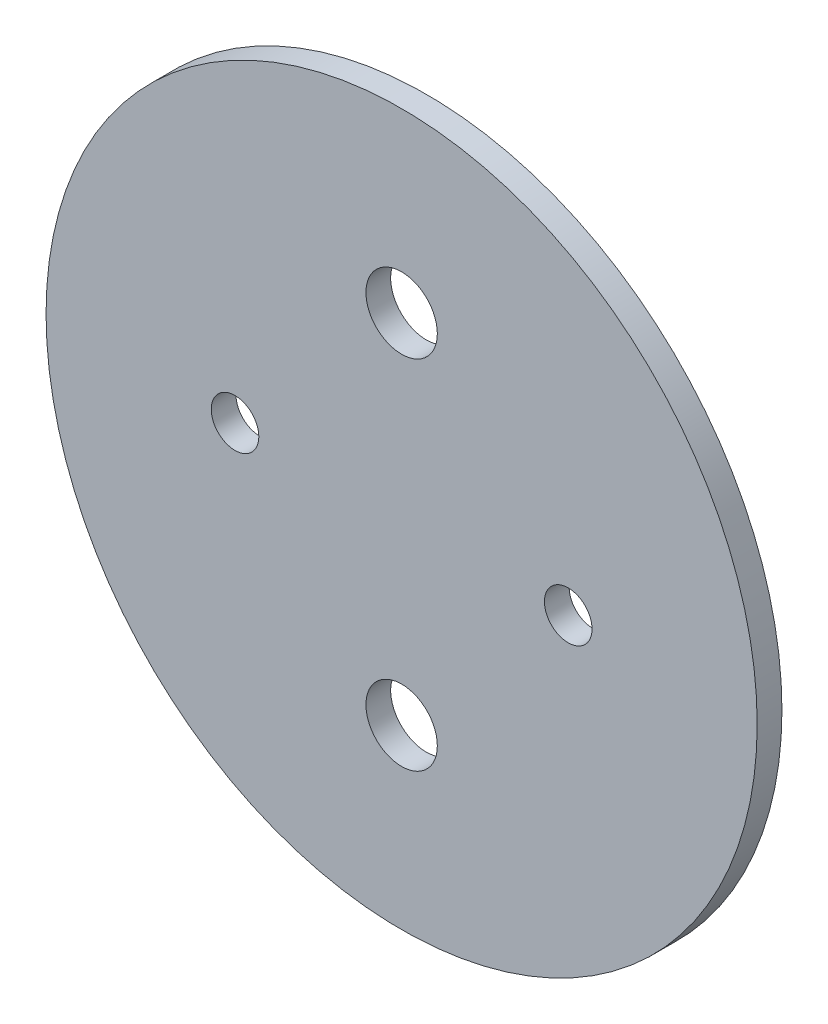
from build123d import *

# Parameters (mm, degrees)
SKETCH1_R           = 47.4345
SKETCH1_R_2         = 3.175
SKETCH1_R_3         = 4.7625
BOSS_EXTRUDE1_DEPTH = 3.302


with BuildPart() as part:
    # Sketch1 → Boss-Extrude1 (new body)
    with BuildSketch(Plane.XY):
        Circle(SKETCH1_R)
        with Locations((-22.225, 0)):
            Circle(SKETCH1_R_2, mode=Mode.SUBTRACT)
        with Locations((22.225, 0)):
            Circle(SKETCH1_R_2, mode=Mode.SUBTRACT)
        with Locations((0, -23.8125)):
            Circle(SKETCH1_R_3, mode=Mode.SUBTRACT)
        with Locations((0, 23.8125)):
            Circle(SKETCH1_R_3, mode=Mode.SUBTRACT)
    extrude(amount=BOSS_EXTRUDE1_DEPTH)


solid = part.part
